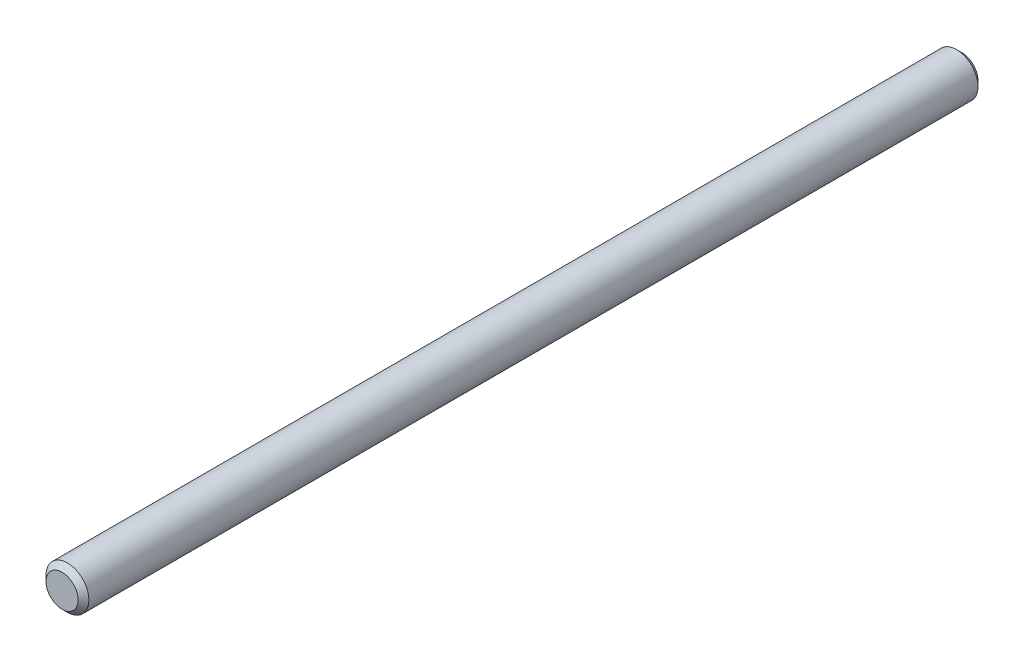
from build123d import *

# Parameters (mm, degrees)
SKETCH1_R           = 2
BOSS_EXTRUDE1_DEPTH = 42
CHAMFER1_SIZE       = 0.5


with BuildPart() as part:
    # Sketch1 → Boss-Extrude1 (new body, symmetric)
    with BuildSketch(Plane.XY):
        Circle(SKETCH1_R)
    extrude(amount=BOSS_EXTRUDE1_DEPTH, both=True)

    # Chamfer1
    chamfer1_edges = [part.edges().sort_by_distance(p)[0] for p in [
        (-2, 0, -42),
        (-2, 0, 42),
    ]]
    chamfer(chamfer1_edges, length=CHAMFER1_SIZE)


solid = part.part
